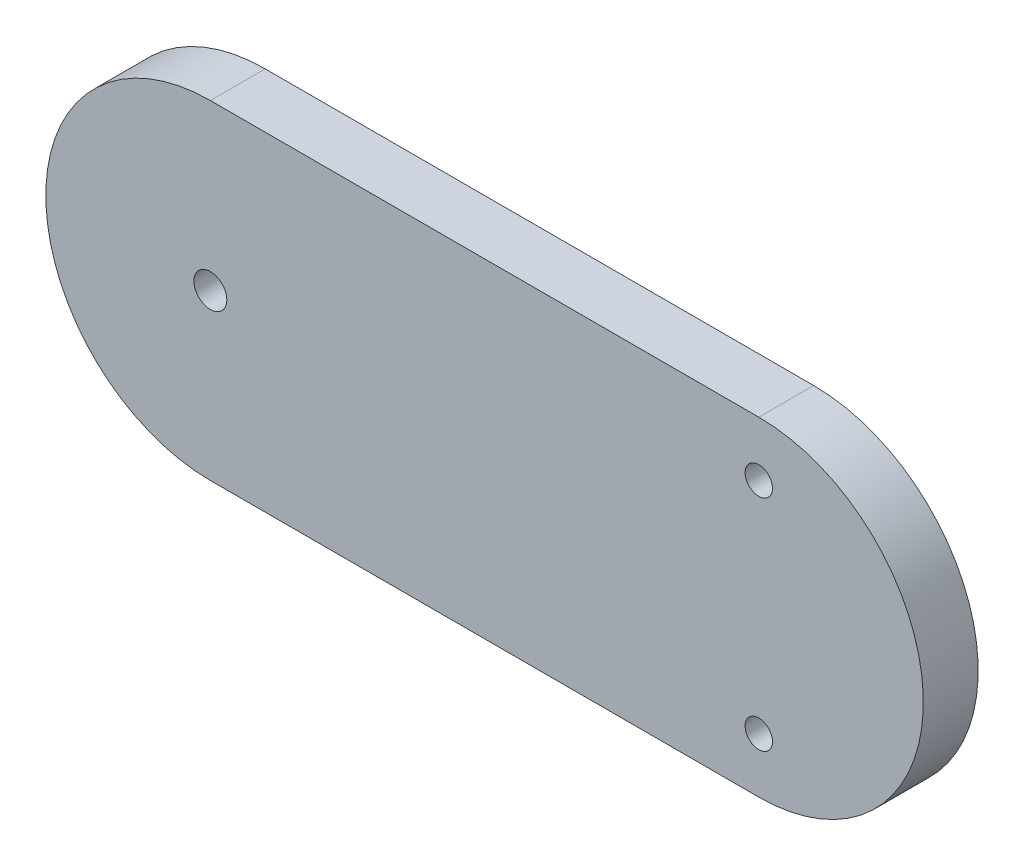
from build123d import *

# Parameters (mm, degrees)
SKETCH1_R           = 1.25
SKETCH1_R_2         = 1.5
BOSS_EXTRUDE1_DEPTH = 5


with BuildPart() as part:
    # Sketch1 → Boss-Extrude1 (new body)
    with BuildSketch(Plane.XY):
        with BuildLine():
            Line((-21.22732467, 15), (28.77267533, 15))
            ThreePointArc((28.77267533, 15), (43.77267533, 0), (28.77267533, -15))
            Line((28.77267533, -15), (-21.22732467, -15))
            ThreePointArc((-21.22732467, -15), (-36.22732467, 0), (-21.22732467, 15))
        make_face()
        with Locations((28.77267533, -10)):
            Circle(SKETCH1_R, mode=Mode.SUBTRACT)
        with Locations((28.77267533, 10)):
            Circle(SKETCH1_R, mode=Mode.SUBTRACT)
        with Locations((-21.22732467, 0)):
            Circle(SKETCH1_R_2, mode=Mode.SUBTRACT)
    extrude(amount=BOSS_EXTRUDE1_DEPTH)


solid = part.part
